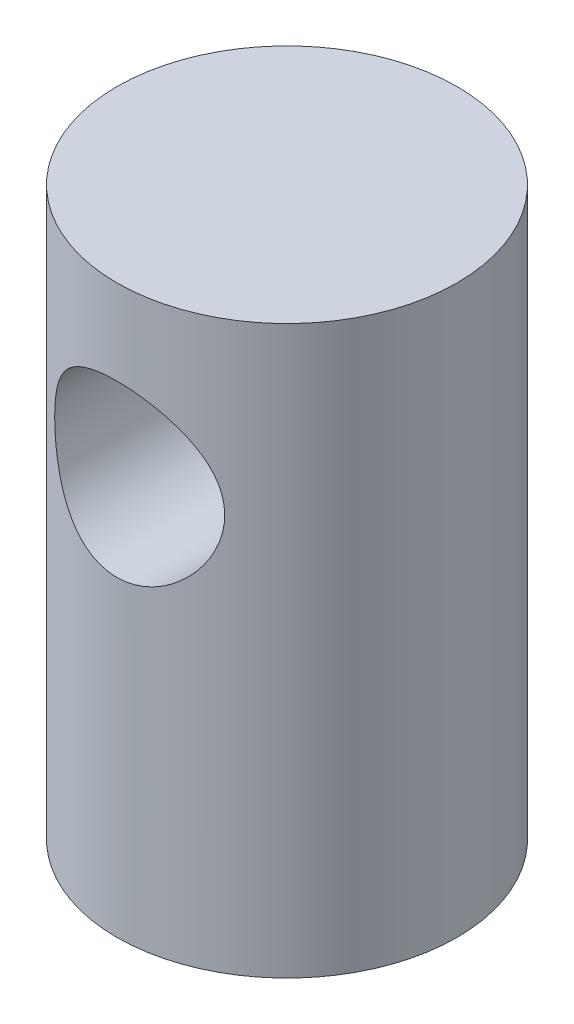
from build123d import *

# Parameters (mm, degrees)
SKETCH1_R                      = 3.81
BOSS_EXTRUDE1_DEPTH            = 12.7
CUT_EXTRUDE1_REACH             = 15.796
CUT_EXTRUDE1_END_RADIUS        = 3.81
SKETCH2_R                      = 1.905
CUT_EXTRUDE1_DIRECTION_2_DEPTH = 19.05


with BuildPart() as part:
    # Sketch1 → Boss-Extrude1 (new body)
    with BuildSketch(Plane(origin=(0, 0, 0), x_dir=(1, 0, 0), z_dir=(0, 1, 0))):
        Circle(SKETCH1_R)
    extrude(amount=BOSS_EXTRUDE1_DEPTH)

    # Cut-Extrude1: up to this cylinder (the profile starts inside it)
    cut_extrude1_end = Plane(origin=(0, 8.89, 0), z_dir=(0, -1, 0)) * Cylinder(CUT_EXTRUDE1_END_RADIUS, 40.212, mode=Mode.PRIVATE)
    # Sketch2 → Cut-Extrude1 (cut, up to the surface)
    with BuildSketch(Plane.XY, mode=Mode.PRIVATE) as cut_extrude1_sk1:
        with Locations((0, 8.89)):
            Circle(SKETCH2_R)
    cut_extrude1_tool1 = extrude(cut_extrude1_sk1.sketch, amount=-CUT_EXTRUDE1_REACH, mode=Mode.PRIVATE) & cut_extrude1_end
    add(cut_extrude1_tool1.solids().sort_by_distance((0, 8.89, 0))[0], mode=Mode.SUBTRACT)

    # Sketch2 → Cut-Extrude1 direction 2 (cut)
    with BuildSketch(Plane.XY):
        with Locations((0, 8.89)):
            Circle(SKETCH2_R)
    extrude(amount=CUT_EXTRUDE1_DIRECTION_2_DEPTH, mode=Mode.SUBTRACT)


solid = part.part
